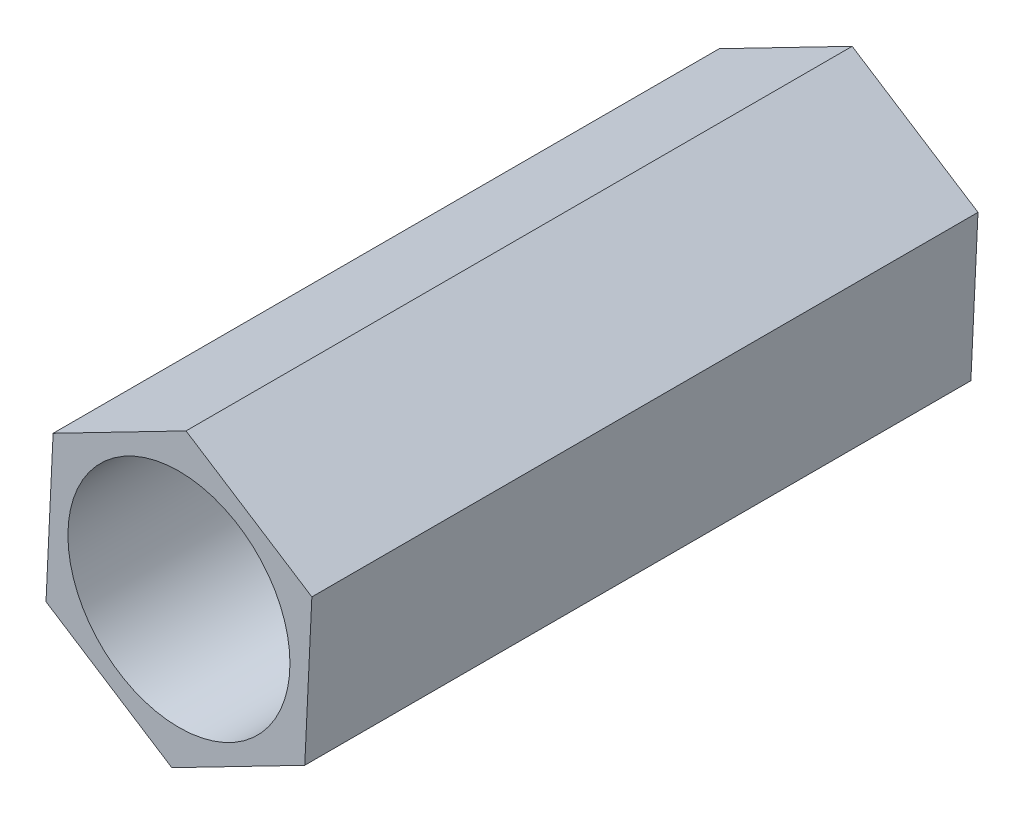
from build123d import *

# Parameters (mm, degrees)
EXTRUDE_1_DEPTH     = 9
SKETCH_2_R          = 1.5
CUT_EXTRUDE_1_DEPTH = 10


with BuildPart() as part:
    # 草图1 → 凸台-拉伸1 (new body)
    with BuildSketch(Plane.XY):
        Polygon((-0.096044396, -2.018442173), (1.7, -1.092397974), (1.796044396, 0.926044199), (0.096044396, 2.018442173), (-1.7, 1.092397974), (-1.796044396, -0.926044199), align=None)
    extrude(amount=-EXTRUDE_1_DEPTH)

    # 草图2 → 切除-拉伸1 (cut, through all)
    with BuildSketch(Plane.XY):
        Circle(SKETCH_2_R)
    extrude(amount=-CUT_EXTRUDE_1_DEPTH, mode=Mode.SUBTRACT)


solid = part.part
